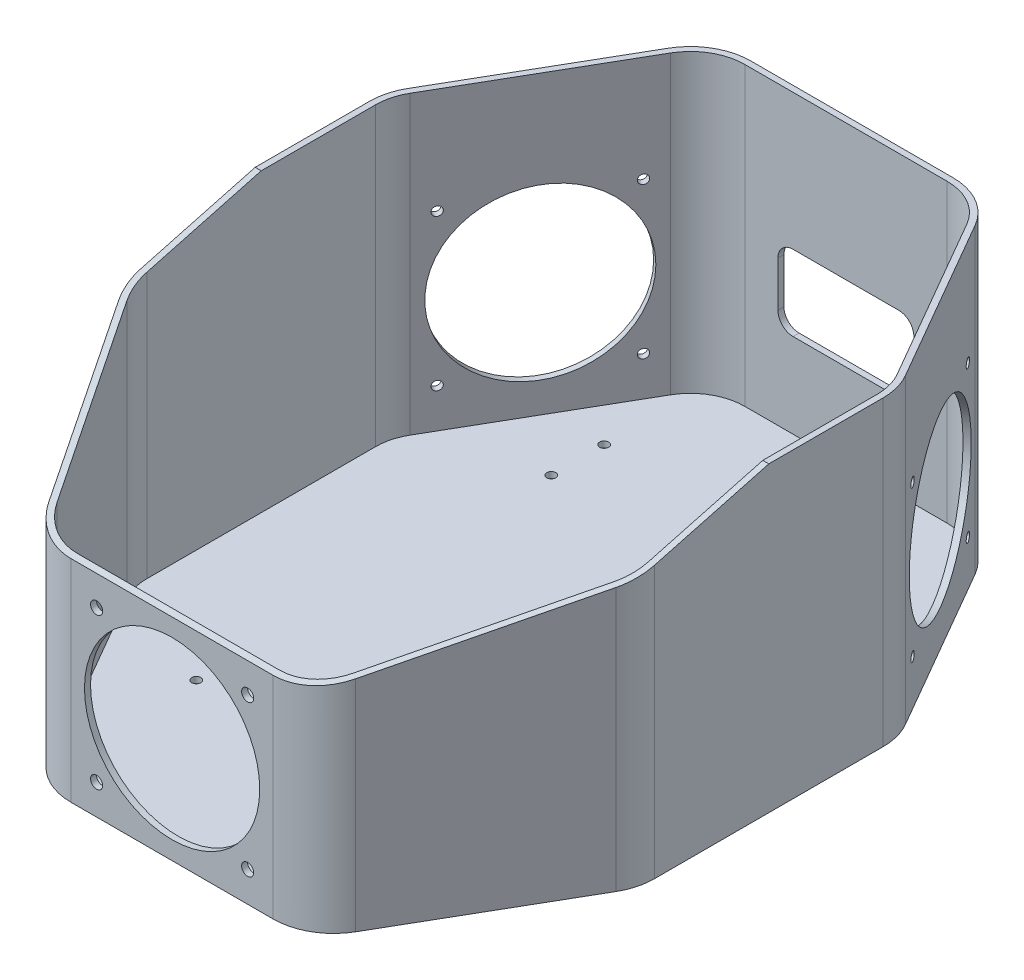
from build123d import *

# Parameters (mm, degrees)
SALIENTE_EXTRUIR1_DEPTH    = 100
VACIADO2_T                 = -2
CROQUIS2_R                 = 1.5
CORTAR_EXTRUIR1_DEPTH      = 101
CORTAR_EXTRUIR1_DEPTH_BACK = 1
CROQUIS8_R                 = 28
CROQUIS8_R_2               = 1.5
CORTAR_EXTRUIR6_DEPTH      = 130.862159322
CORTAR_EXTRUIR7_DEPTH      = 113.5
CORTAR_EXTRUIR8_DEPTH      = 86
CORTAR_EXTRUIR8_DEPTH_BACK = 86
CROQUIS11_R                = 29
CROQUIS11_R_2              = 2
CORTAR_EXTRUIR9_DEPTH      = 113.5


with BuildPart() as part:
    # Croquis1 → Saliente-Extruir1 (new body)
    with BuildSketch(Plane(origin=(0, 0, 0), x_dir=(1, 0, 0), z_dir=(0, 1, 0))):
        with BuildLine():
            Line((-82.320508076, 47.858983849), (-50.773502692, 102.5))
            ThreePointArc((-50.773502692, 102.5), (-43.452994616, 109.820508076), (-33.452994616, 112.5))
            Line((-33.452994616, 112.5), (33.452994616, 112.5))
            ThreePointArc((33.452994616, 112.5), (43.452994616, 109.820508076), (50.773502692, 102.5))
            Line((50.773502692, 102.5), (82.320508076, 47.858983849))
            ThreePointArc((82.320508076, 47.858983849), (84.318516526, 43.035364751), (85, 37.858983849))
            Line((85, 37.858983849), (85, -37.858983849))
            ThreePointArc((85, -37.858983849), (84.318516526, -43.035364751), (82.320508076, -47.858983849))
            Line((82.320508076, -47.858983849), (50.773502692, -102.5))
            ThreePointArc((50.773502692, -102.5), (43.452994616, -109.820508076), (33.452994616, -112.5))
            Line((33.452994616, -112.5), (-33.452994616, -112.5))
            ThreePointArc((-33.452994616, -112.5), (-43.452994616, -109.820508076), (-50.773502692, -102.5))
            Line((-50.773502692, -102.5), (-82.320508076, -47.858983849))
            ThreePointArc((-82.320508076, -47.858983849), (-84.318516526, -43.035364751), (-85, -37.858983849))
            Line((-85, -37.858983849), (-85, 37.858983849))
            ThreePointArc((-85, 37.858983849), (-84.318516526, 43.035364751), (-82.320508076, 47.858983849))
        make_face()
    extrude(amount=SALIENTE_EXTRUIR1_DEPTH)

    # Vaciado2
    vaciado2_openings = [part.faces().sort_by_distance(p)[0] for p in [
        (0, 100, 0),
    ]]
    offset(amount=VACIADO2_T, openings=vaciado2_openings, kind=Kind.INTERSECTION)

    # Croquis2 → Cortar-Extruir1 (cut, two sides)
    with BuildSketch(Plane(origin=(0, 0, 0), x_dir=(1, 0, 0), z_dir=(0, 1, 0))) as cortar_extruir1_sk:
        with Locations((-45.75, 76.25)):
            Circle(CROQUIS2_R)
        with Locations((-45.75, 58.75)):
            Circle(CROQUIS2_R)
        with Locations((45.75, 58.75)):
            Circle(CROQUIS2_R)
        with Locations((-45.75, -58.75)):
            Circle(CROQUIS2_R)
        with Locations((45.75, -58.75)):
            Circle(CROQUIS2_R)
        with Locations((45.75, -76.25)):
            Circle(CROQUIS2_R)
    extrude(amount=CORTAR_EXTRUIR1_DEPTH, mode=Mode.SUBTRACT)
    extrude(cortar_extruir1_sk.sketch, amount=-CORTAR_EXTRUIR1_DEPTH_BACK, mode=Mode.SUBTRACT)

    # Croquis8 → Cortar-Extruir6 (cut, through all)
    with BuildSketch(Plane(origin=(0, 0, 0), x_dir=(-0.5, 0, -0.866025404), z_dir=(0.866025404, 0, -0.5))):
        with Locations((31.833847158, 40)):
            Circle(CROQUIS8_R)
        with Locations((6.833847158, 65)):
            Circle(CROQUIS8_R_2)
        with Locations((56.833847158, 65)):
            Circle(CROQUIS8_R_2)
        with Locations((6.833847158, 15)):
            Circle(CROQUIS8_R_2)
        with Locations((56.833847158, 15)):
            Circle(CROQUIS8_R_2)
    cortar_extruir6 = extrude(amount=CORTAR_EXTRUIR6_DEPTH, mode=Mode.SUBTRACT)

    # Simetría1: Cortar-Extruir6 across plane
    add(cortar_extruir6.mirror(Plane(origin=(0, 0, 0), x_dir=(0, 0, 1), z_dir=(1, 0, 0))), mode=Mode.SUBTRACT)

    # Croquis9 → Cortar-Extruir7 (cut, through all)
    with BuildSketch(Plane.XY):
        with BuildLine():
            Line((17.5, 55), (-17.5, 55))
            ThreePointArc((-17.5, 55), (-21.035533906, 53.535533906), (-22.5, 50))
            Line((-22.5, 50), (-22.5, 35))
            ThreePointArc((-22.5, 35), (-21.035533906, 31.464466094), (-17.5, 30))
            Line((-17.5, 30), (17.5, 30))
            ThreePointArc((17.5, 30), (21.035533906, 31.464466094), (22.5, 35))
            Line((22.5, 35), (22.5, 50))
            ThreePointArc((22.5, 50), (21.035533906, 53.535533906), (17.5, 55))
        make_face()
    extrude(amount=-CORTAR_EXTRUIR7_DEPTH, mode=Mode.SUBTRACT)

    # Croquis10 → Cortar-Extruir8 (cut, two sides)
    with BuildSketch(Plane(origin=(0, 0, 0), x_dir=(0, 0, -1), z_dir=(1, 0, 0))) as cortar_extruir8_sk:
        Polygon((0, 100), (-148.82762011, 60.12175938), (-148.82762011, 114.287226581), (0, 114.287226581), align=None)
    extrude(amount=CORTAR_EXTRUIR8_DEPTH, mode=Mode.SUBTRACT)
    extrude(cortar_extruir8_sk.sketch, amount=-CORTAR_EXTRUIR8_DEPTH_BACK, mode=Mode.SUBTRACT)

    # Croquis11 → Cortar-Extruir9 (cut, through all)
    with BuildSketch(Plane.XY):
        with Locations((0, 35)):
            Circle(CROQUIS11_R)
        with Locations((25, 10)):
            Circle(CROQUIS11_R_2)
        with Locations((-25, 10)):
            Circle(CROQUIS11_R_2)
        with Locations((-25, 60)):
            Circle(CROQUIS11_R_2)
        with Locations((25, 60)):
            Circle(CROQUIS11_R_2)
    extrude(amount=CORTAR_EXTRUIR9_DEPTH, mode=Mode.SUBTRACT)


solid = part.part
